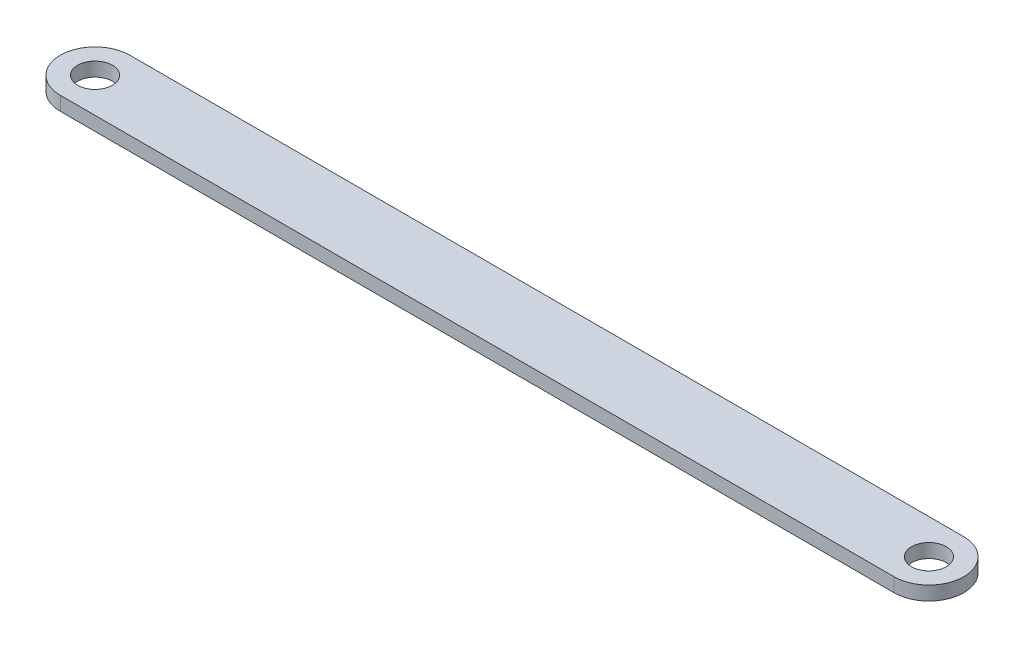
from build123d import *

# Parameters (mm, degrees)
SKETCH1_R           = 3.175
BOSS_EXTRUDE1_DEPTH = 2.54


with BuildPart() as part:
    # Sketch1 → Boss-Extrude1 (new body)
    with BuildSketch(Plane(origin=(0, 0, 0), x_dir=(1, 0, 0), z_dir=(0, 1, 0))):
        with BuildLine():
            Line((-76.2, -6.35), (76.2, -6.35))
            ThreePointArc((76.2, -6.35), (82.55, 0), (76.2, 6.35))
            Line((76.2, 6.35), (-76.2, 6.35))
            ThreePointArc((-76.2, 6.35), (-82.55, 0), (-76.2, -6.35))
        make_face()
        with Locations((-76.2, 0)):
            Circle(SKETCH1_R, mode=Mode.SUBTRACT)
        with Locations((76.2, 0)):
            Circle(SKETCH1_R, mode=Mode.SUBTRACT)
    extrude(amount=BOSS_EXTRUDE1_DEPTH)


solid = part.part
